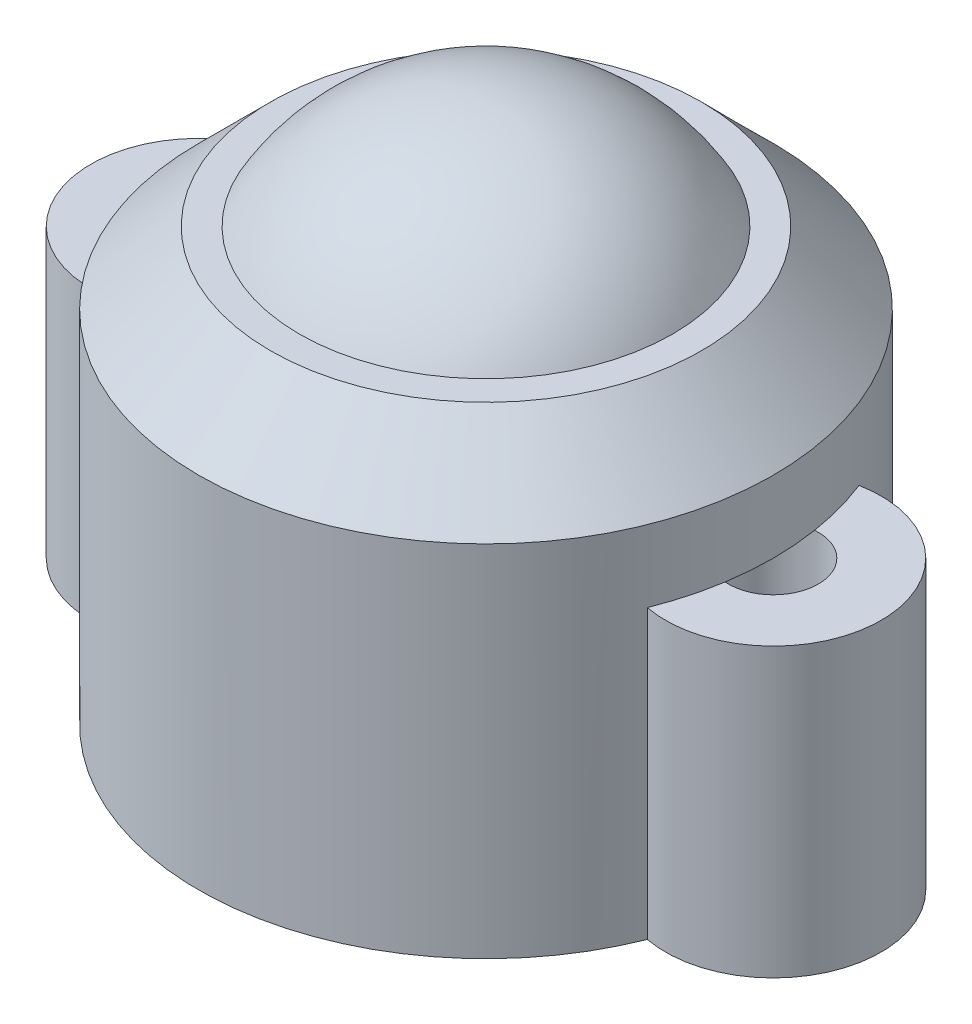
from build123d import *

# Parameters (mm, degrees)
SKETCH1_R           = 1.25
BOSS_EXTRUDE1_DEPTH = 8
SKETCH2_R           = 8
BOSS_EXTRUDE2_DEPTH = 4
CHAMFER1_SIZE       = 2


with BuildPart() as part:
    # Sketch1 → Boss-Extrude1 (new body)
    with BuildSketch(Plane(origin=(0, 0, 0), x_dir=(1, 0, 0), z_dir=(0, 1, 0))):
        with BuildLine():
            ThreePointArc((7.4375, -2.946793809), (11, 0), (7.4375, 2.946793809))
            ThreePointArc((7.4375, 2.946793809), (0, 8), (-7.4375, 2.946793809))
            ThreePointArc((-7.4375, 2.946793809), (-11, 0), (-7.4375, -2.946793809))
            ThreePointArc((-7.4375, -2.946793809), (0, -8), (7.4375, -2.946793809))
        make_face()
        with Locations((8, 0)):
            Circle(SKETCH1_R, mode=Mode.SUBTRACT)
        with Locations((-8, 0)):
            Circle(SKETCH1_R, mode=Mode.SUBTRACT)
    extrude(amount=BOSS_EXTRUDE1_DEPTH)

    # Sketch2 → Boss-Extrude2 (add)
    with BuildSketch(Plane(origin=(0, 8, 0), x_dir=(1, 0, 0), z_dir=(0, 1, 0))):
        Circle(SKETCH2_R)
    extrude(amount=BOSS_EXTRUDE2_DEPTH)

    # Chamfer1
    chamfer1_edges = [part.edges().sort_by_distance(p)[0] for p in [
        (-8, 12, 0),
    ]]
    chamfer(chamfer1_edges, length=CHAMFER1_SIZE)

    # Sketch3 → Revolve2 (revolve)
    with BuildSketch(Plane.XY):
        with BuildLine():
            Line((0, 15), (0, 3))
            ThreePointArc((0, 3), (6, 9), (0, 15))
        make_face()
    revolve(axis=Axis((0, 12, 0), (0, -1, 0)))


solid = part.part
